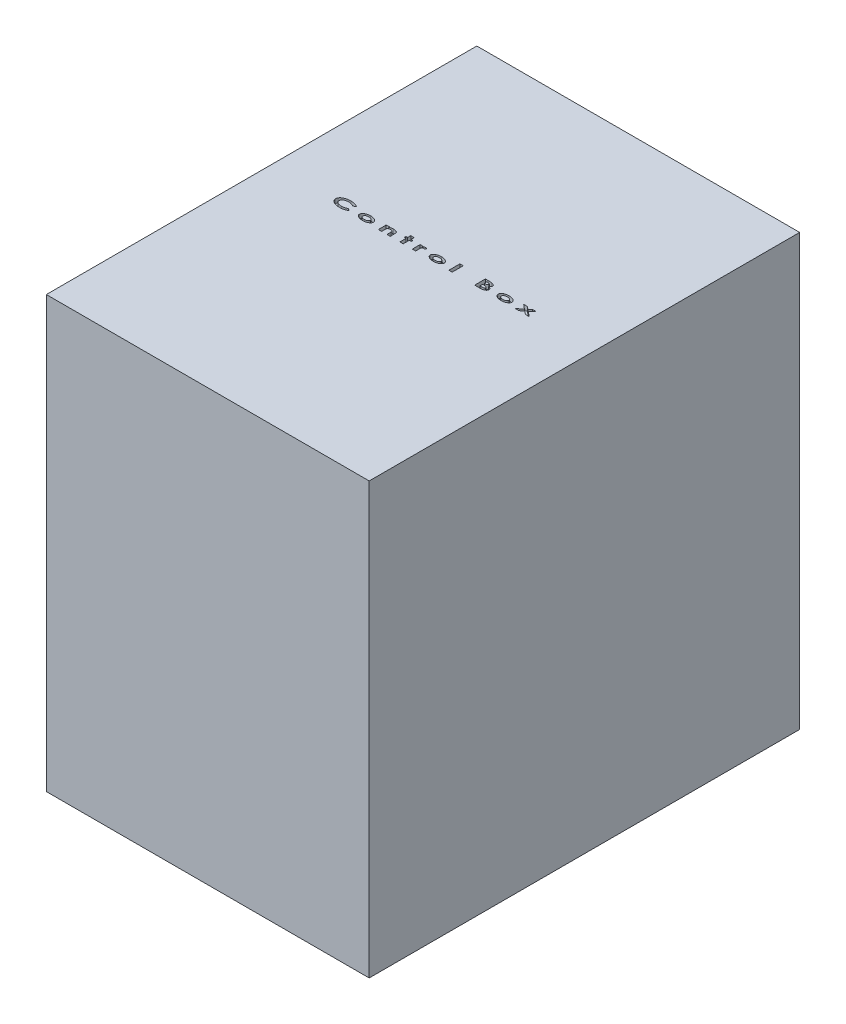
from build123d import *

# Parameters (mm, degrees)
SKETCH1_W           = 150
SKETCH1_H           = 200
BOSS_EXTRUDE1_DEPTH = 200
SKETCH5_W           = 1.538461538
SKETCH5_H           = 5.128205128
CUT_EXTRUDE1_DEPTH  = 2


with BuildPart() as part:
    # Sketch1 → Boss-Extrude1 (new body)
    with BuildSketch(Plane(origin=(0, 0, 0), x_dir=(1, 0, 0), z_dir=(0, 1, 0))):
        with Locations((3.387096774, 4.032258065)):
            Rectangle(SKETCH1_W, SKETCH1_H)
    extrude(amount=BOSS_EXTRUDE1_DEPTH)

    # Sketch5 → Cut-Extrude1 (cut)
    with BuildSketch(Plane(origin=(0, 200, 0), x_dir=(1, 0, 0), z_dir=(0, 1, 0))):
        with BuildLine():
            Line((-34.940086456, 11.453408643), (-36.047858891, 10.824402233))
            add(Edge.make_bspline(
                [(-36.047858891, 10.824402233), (-36.142518363, 10.882607239), (-36.331333147, 10.99870725), (-36.628305726, 11.14641812), (-36.934151745, 11.270341641), (-37.247432659, 11.375064909), (-37.570982515, 11.453348387), (-37.902861291, 11.510511466), (-38.243615225, 11.545606536), (-38.473657359, 11.549564994), (-38.589926199, 11.551565695)],
                knots=[0, 0, 0, 0, 0.000333243, 0.000664712, 0.000993555, 0.001322643, 0.001654724, 0.001991134, 0.002332381, 0.002681113, 0.002681113, 0.002681113, 0.002681113], degree=3))
            add(Edge.make_bspline(
                [(-38.589926199, 11.551565695), (-38.687458788, 11.549988829), (-38.878795575, 11.546895377), (-39.159821776, 11.523738404), (-39.428713565, 11.484673719), (-39.68622642, 11.430982633), (-39.93179496, 11.360679845), (-40.166181353, 11.275912126), (-40.388214953, 11.174043662), (-40.596736069, 11.059290251), (-40.787389507, 10.933495209), (-40.954596669, 10.798410397), (-41.096441269, 10.655821362), (-41.212028332, 10.505402128), (-41.302767967, 10.347627171), (-41.367429412, 10.181995958), (-41.406908919, 10.008604551), (-41.411917667, 9.890444348), (-41.41444543, 9.83081249)],
                knots=[0, 0, 0, 0, 0.000292578, 0.000573971, 0.000845228, 0.00110728, 0.001362493, 0.00161091, 0.001854285, 0.002094578, 0.002324314, 0.002538622, 0.002738351, 0.00292626, 0.00310615, 0.003282478, 0.00345793, 0.00363669, 0.00363669, 0.00363669, 0.00363669], degree=3))
            add(Edge.make_bspline(
                [(-41.41444543, 9.83081249), (-41.413253838, 9.789019266), (-41.410898797, 9.706419854), (-41.39321482, 9.58436284), (-41.365293839, 9.465968917), (-41.326289537, 9.350967355), (-41.274432848, 9.240307857), (-41.211997759, 9.132801978), (-41.138816761, 9.028134812), (-41.053444829, 8.928402077), (-40.958005648, 8.833348763), (-40.853454156, 8.742696327), (-40.738940823, 8.657896739), (-40.61574743, 8.577539652), (-40.482698911, 8.503358074), (-40.34043434, 8.434471768), (-40.188917119, 8.370535686), (-40.02937831, 8.311331356), (-39.862218893, 8.260099724), (-39.690120662, 8.213351644), (-39.512773481, 8.175763545), (-39.331253654, 8.14507952), (-39.145651975, 8.119201968), (-38.955049781, 8.103249962), (-38.760020724, 8.091131621), (-38.628341043, 8.090397666), (-38.561881327, 8.090027233)],
                knots=[0, 0, 0, 0, 0.000125344, 0.000247729, 0.0003692, 0.000489879, 0.000611321, 0.000735184, 0.000862451, 0.000993905, 0.001128471, 0.001266227, 0.001408655, 0.001555618, 0.001707188, 0.001865317, 0.002029583, 0.002200388, 0.002375577, 0.002553907, 0.00273523, 0.00291916, 0.003106141, 0.003297206, 0.003492829, 0.00369217, 0.00369217, 0.00369217, 0.00369217], degree=3))
            add(Edge.make_bspline(
                [(-38.561881327, 8.090027233), (-38.449307157, 8.091967203), (-38.2287817, 8.095767477), (-37.905480838, 8.125038508), (-37.597312164, 8.17402186), (-37.34947334, 8.231076545), (-37.155112027, 8.288709427), (-37.007482101, 8.341322462), (-36.85567906, 8.400415908), (-36.70067376, 8.467585835), (-36.54186218, 8.542833804), (-36.380348012, 8.627272764), (-36.214436595, 8.718323381), (-36.104096085, 8.783812757), (-36.047858891, 8.817190695)],
                knots=[0, 0, 0, 0, 0.000337689, 0.00066151, 0.000972894, 0.001273188, 0.001423712, 0.001580832, 0.00174321, 0.001912341, 0.002087518, 0.002270294, 0.002459026, 0.002655202, 0.002655202, 0.002655202, 0.002655202], degree=3))
            Line((-36.047858891, 8.817190695), (-34.974140943, 8.147118579))
            add(Edge.make_bspline(
                [(-34.974140943, 8.147118579), (-35.049687253, 8.103619875), (-35.198625273, 8.01786306), (-35.422899403, 7.898532232), (-35.644820916, 7.790589572), (-35.862529414, 7.691161807), (-36.077442712, 7.602247119), (-36.289842345, 7.526034682), (-36.498093627, 7.456788137), (-36.705591511, 7.399730237), (-36.914674905, 7.349993594), (-37.129635824, 7.308297967), (-37.351371219, 7.27207744), (-37.580611734, 7.243402992), (-37.816704981, 7.220047947), (-38.060586574, 7.204619368), (-38.311385572, 7.193982797), (-38.481073851, 7.193058683), (-38.56688934, 7.192591336)],
                knots=[0, 0, 0, 0, 0.000261512, 0.000515566, 0.000761938, 0.001001748, 0.001233506, 0.001459418, 0.001678602, 0.00189172, 0.002104781, 0.002323213, 0.002548474, 0.002778679, 0.003016177, 0.003260093, 0.003511695, 0.003769124, 0.003769124, 0.003769124, 0.003769124], degree=3))
            add(Edge.make_bspline(
                [(-38.56688934, 7.192591336), (-38.646359916, 7.193132112), (-38.803683353, 7.194202657), (-39.036766173, 7.203822916), (-39.264253217, 7.21731823), (-39.486026619, 7.237488402), (-39.702502567, 7.263325086), (-39.913487452, 7.295711101), (-40.119534119, 7.332024157), (-40.319648177, 7.376909017), (-40.514750186, 7.425001654), (-40.703755831, 7.481185006), (-40.88812271, 7.540136508), (-41.066093062, 7.607908997), (-41.239036651, 7.679875796), (-41.406460583, 7.758066717), (-41.568368211, 7.842204482), (-41.724517794, 7.930713666), (-41.872177956, 8.024921008), (-42.01196448, 8.121913309), (-42.141682638, 8.222578548), (-42.261796827, 8.326795397), (-42.373402632, 8.432961633), (-42.472981891, 8.545000305), (-42.565313192, 8.657992419), (-42.646214217, 8.775693609), (-42.718509264, 8.896085699), (-42.782243225, 9.019075095), (-42.834265065, 9.146379058), (-42.877283184, 9.276599996), (-42.911667796, 9.410026793), (-42.935602612, 9.546653151), (-42.949856496, 9.686611059), (-42.951882064, 9.781033229), (-42.952906968, 9.828809284)],
                knots=[0, 0, 0, 0, 0.0002384, 0.000471948, 0.000699744, 0.000922002, 0.00113991, 0.001353665, 0.001562311, 0.001767422, 0.001968806, 0.002165, 0.002358846, 0.002549343, 0.002736103, 0.002920716, 0.003103492, 0.003283382, 0.003458991, 0.003628762, 0.00379365, 0.003951287, 0.004105709, 0.004255351, 0.004400669, 0.0045432, 0.004683367, 0.004821784, 0.004958311, 0.005095457, 0.005232954, 0.005371277, 0.005511204, 0.005654521, 0.005654521, 0.005654521, 0.005654521], degree=3))
            add(Edge.make_bspline(
                [(-42.952906968, 9.828809284), (-42.951123925, 9.890334178), (-42.947580603, 10.01259849), (-42.920788993, 10.192755445), (-42.877968267, 10.36825239), (-42.815034908, 10.537208966), (-42.736432511, 10.702103503), (-42.640269624, 10.861203759), (-42.525600222, 11.014584047), (-42.394252177, 11.162267755), (-42.247157011, 11.304947684), (-42.082661497, 11.438342149), (-41.905436988, 11.567684398), (-41.711403596, 11.686890717), (-41.503401545, 11.800800468), (-41.279959875, 11.90619921), (-41.041788394, 12.005782529), (-40.789966843, 12.096917717), (-40.528045319, 12.179664609), (-40.25934907, 12.251807584), (-39.985642159, 12.312790344), (-39.707053569, 12.363322186), (-39.423489855, 12.400479886), (-39.135294071, 12.42934725), (-38.841837219, 12.445013698), (-38.644363029, 12.447665385), (-38.544854084, 12.449001592)],
                knots=[0, 0, 0, 0, 0.000184515, 0.000366675, 0.000545224, 0.000725527, 0.000906518, 0.001092549, 0.001282254, 0.00148022, 0.001684932, 0.001896279, 0.002115062, 0.002342691, 0.002578903, 0.00282621, 0.003083468, 0.003353107, 0.003629335, 0.003907283, 0.004187464, 0.004470377, 0.004756374, 0.005045199, 0.005339106, 0.005637644, 0.005637644, 0.005637644, 0.005637644], degree=3))
            add(Edge.make_bspline(
                [(-38.544854084, 12.449001592), (-38.460036404, 12.448246306), (-38.290983991, 12.446740924), (-38.038466458, 12.434150442), (-37.788159791, 12.414816541), (-37.540486656, 12.384812707), (-37.295030662, 12.349797276), (-37.052475166, 12.303691351), (-36.811640091, 12.252394465), (-36.574632751, 12.191138906), (-36.34232455, 12.123424523), (-36.117589973, 12.048284967), (-35.900258261, 11.967623216), (-35.692262201, 11.877849149), (-35.49154489, 11.783410093), (-35.299806932, 11.680351584), (-35.115199406, 11.572282823), (-34.998097569, 11.492789074), (-34.940086456, 11.453408643)],
                knots=[0, 0, 0, 0, 0.000254439, 0.000507128, 0.000758329, 0.001007424, 0.001255452, 0.001501995, 0.001747957, 0.001994044, 0.002236191, 0.002473742, 0.0027048, 0.002931404, 0.003153174, 0.003370051, 0.003584256, 0.003794547, 0.003794547, 0.003794547, 0.003794547], degree=3))
        make_face()
        with BuildLine():
            add(Edge.make_bspline(
                [(-27.989966263, 11.038745182), (-27.91683363, 11.037981755), (-27.771804367, 11.036467803), (-27.555952648, 11.024154129), (-27.343554207, 11.003799985), (-27.134194849, 10.977522073), (-26.928441668, 10.941059553), (-26.726135081, 10.896640634), (-26.526563738, 10.846388986), (-26.33247435, 10.785882703), (-26.144741213, 10.720539128), (-25.966356963, 10.648780273), (-25.798943328, 10.570085946), (-25.640841808, 10.487836851), (-25.495244962, 10.397041813), (-25.358488831, 10.30305797), (-25.233683015, 10.201812544), (-25.119383038, 10.095907635), (-25.017336872, 9.986284537), (-24.92840151, 9.87347773), (-24.853193681, 9.758556024), (-24.791279809, 9.64126154), (-24.742804271, 9.521914148), (-24.708578591, 9.399989182), (-24.687948423, 9.275959671), (-24.685102478, 9.192534069), (-24.683676199, 9.150724349)],
                knots=[0, 0, 0, 0, 0.000219388, 0.000435067, 0.00064835, 0.000859424, 0.001067895, 0.001274963, 0.001480723, 0.001685072, 0.00188464, 0.002076958, 0.002261571, 0.002439445, 0.002611231, 0.002775997, 0.002936959, 0.003092875, 0.003243129, 0.003385793, 0.003523308, 0.003654579, 0.003783101, 0.003908989, 0.004033804, 0.0041592, 0.0041592, 0.0041592, 0.0041592], degree=3))
            add(Edge.make_bspline(
                [(-24.683676199, 9.150724349), (-24.685137243, 9.108592051), (-24.68805248, 9.02452502), (-24.70817434, 8.899250488), (-24.744404428, 8.776977902), (-24.790984109, 8.655474), (-24.853913844, 8.537549413), (-24.929861776, 8.421405672), (-25.019321283, 8.307165528), (-25.121994564, 8.195828896), (-25.236606593, 8.088967853), (-25.360519679, 7.986046272), (-25.496657917, 7.891859837), (-25.640627981, 7.800910388), (-25.795606529, 7.718049376), (-25.960367868, 7.641170764), (-26.134462516, 7.568651157), (-26.318277609, 7.504280815), (-26.509182546, 7.446506133), (-26.705529166, 7.395158052), (-26.906764768, 7.352327479), (-27.11290845, 7.317085439), (-27.323784897, 7.290181634), (-27.53965878, 7.271584004), (-27.760113723, 7.25886651), (-27.908818288, 7.25742319), (-27.983956648, 7.2566939)],
                knots=[0, 0, 0, 0, 0.000126397, 0.0002522, 0.000379325, 0.000508407, 0.000641918, 0.000779433, 0.000924292, 0.001076697, 0.001233296, 0.001394115, 0.001559456, 0.001729539, 0.001904763, 0.00208623, 0.00227484, 0.002470296, 0.002670228, 0.002873079, 0.003078956, 0.003287256, 0.003500317, 0.003716501, 0.003937181, 0.004162578, 0.004162578, 0.004162578, 0.004162578], degree=3))
            add(Edge.make_bspline(
                [(-27.983956648, 7.2566939), (-28.093843333, 7.258546395), (-28.309564873, 7.26218308), (-28.627040339, 7.287201236), (-28.932075298, 7.330220809), (-29.225149628, 7.390281212), (-29.506298234, 7.466745403), (-29.774274748, 7.562774947), (-30.030921587, 7.673567396), (-30.234014718, 7.781402567), (-30.387447619, 7.874937229), (-30.495575093, 7.946034844), (-30.595163554, 8.020068892), (-30.687943964, 8.095372189), (-30.77326415, 8.172554321), (-30.851216638, 8.251427418), (-30.922288683, 8.332007052), (-30.984778188, 8.41519015), (-31.042011481, 8.499353955), (-31.089354508, 8.586753576), (-31.131274452, 8.674981578), (-31.16403373, 8.765701377), (-31.190445552, 8.857630925), (-31.208313552, 8.951860812), (-31.219621848, 9.04761761), (-31.221297798, 9.112298463), (-31.222137738, 9.144714733)],
                knots=[0, 0, 0, 0, 0.000329651, 0.000647146, 0.000954664, 0.001253242, 0.001544102, 0.001827954, 0.002106511, 0.00238207, 0.002516915, 0.002645534, 0.002770136, 0.002889023, 0.003003898, 0.003115094, 0.003221566, 0.003325934, 0.003427052, 0.003526574, 0.003623812, 0.003719825, 0.003815581, 0.003910459, 0.004007242, 0.00410448, 0.00410448, 0.00410448, 0.00410448], degree=3))
            add(Edge.make_bspline(
                [(-31.222137738, 9.144714733), (-31.221471318, 9.179482111), (-31.220146494, 9.248598696), (-31.206317577, 9.351049634), (-31.185618845, 9.451265318), (-31.156182366, 9.549008745), (-31.119168805, 9.644691933), (-31.072802217, 9.738151293), (-31.017363536, 9.829261786), (-30.954041098, 9.91856634), (-30.88295717, 10.00574795), (-30.803219998, 10.090336675), (-30.714884577, 10.172232281), (-30.61846925, 10.252290618), (-30.514348307, 10.330952472), (-30.400342136, 10.405257858), (-30.279631342, 10.480324855), (-30.194110886, 10.525754115), (-30.150422994, 10.548961528)],
                knots=[0, 0, 0, 0, 0.000104244, 0.000207234, 0.000309579, 0.000410983, 0.000513097, 0.000617018, 0.000723518, 0.000832734, 0.000945209, 0.001060706, 0.001181182, 0.001306346, 0.001436554, 0.001572396, 0.001714458, 0.00186282, 0.00186282, 0.00186282, 0.00186282], degree=3))
            add(Edge.make_bspline(
                [(-30.150422994, 10.548961528), (-30.071170863, 10.58854834), (-29.912128223, 10.667990888), (-29.662711469, 10.765955091), (-29.405646502, 10.850599586), (-29.139760361, 10.919885199), (-28.864658974, 10.972637719), (-28.580750063, 11.010448088), (-28.288175486, 11.03405283), (-28.090170938, 11.037168451), (-27.989966263, 11.038745182)],
                knots=[0, 0, 0, 0, 0.000265653, 0.000533111, 0.000802972, 0.001077247, 0.001356773, 0.00164277, 0.001936144, 0.002236731, 0.002236731, 0.002236731, 0.002236731], degree=3))
        make_face()
        with BuildLine():
            add(Edge.make_bspline(
                [(-27.955911776, 10.205411849), (-28.01635418, 10.204250636), (-28.135041162, 10.201970434), (-28.30917575, 10.189986766), (-28.47512024, 10.164797837), (-28.634051729, 10.133774604), (-28.784687716, 10.091207812), (-28.928635052, 10.041740286), (-29.063312027, 9.979968182), (-29.189971718, 9.91182917), (-29.305239466, 9.836468634), (-29.405417292, 9.754010969), (-29.492296624, 9.667985221), (-29.561747105, 9.574822457), (-29.616962913, 9.47715085), (-29.655191179, 9.373305225), (-29.678946586, 9.264644395), (-29.682090892, 9.190240684), (-29.683676199, 9.152727554)],
                knots=[0, 0, 0, 0, 0.000181359, 0.000356124, 0.000523127, 0.000684594, 0.000841577, 0.000992364, 0.001140743, 0.001285509, 0.001423574, 0.001553102, 0.001674213, 0.001789398, 0.001900593, 0.002009616, 0.002120215, 0.002232681, 0.002232681, 0.002232681, 0.002232681], degree=3))
            add(Edge.make_bspline(
                [(-29.683676199, 9.152727554), (-29.682017327, 9.113900832), (-29.678758036, 9.037615494), (-29.656517756, 8.926043435), (-29.617892721, 8.820381775), (-29.563107681, 8.721010646), (-29.494020556, 8.626853718), (-29.410199281, 8.538066348), (-29.310141476, 8.456083908), (-29.195978495, 8.380731881), (-29.070861838, 8.311932451), (-28.93564283, 8.253353221), (-28.793450639, 8.201646224), (-28.642529292, 8.161062104), (-28.48394477, 8.129093956), (-28.317071661, 8.105874443), (-28.142068908, 8.093356653), (-28.02270351, 8.091150586), (-27.961921391, 8.090027233)],
                knots=[0, 0, 0, 0, 0.000116462, 0.00022882, 0.000339722, 0.000452673, 0.000568066, 0.000689227, 0.000817982, 0.000955213, 0.001099099, 0.001245747, 0.00139687, 0.001552622, 0.001714088, 0.001881942, 0.002057706, 0.002240066, 0.002240066, 0.002240066, 0.002240066], degree=3))
            add(Edge.make_bspline(
                [(-27.961921391, 8.090027233), (-27.900795423, 8.091010613), (-27.781383609, 8.092931681), (-27.606159878, 8.107313652), (-27.438928579, 8.130118164), (-27.279113851, 8.161696418), (-27.127351081, 8.204236747), (-26.983179344, 8.254797282), (-26.846802096, 8.315316584), (-26.719792424, 8.384626514), (-26.60404563, 8.461181173), (-26.501648932, 8.542980168), (-26.416012274, 8.631892557), (-26.344765153, 8.725212531), (-26.290181952, 8.824611187), (-26.250308241, 8.928915721), (-26.226880557, 9.039179365), (-26.223732071, 9.114557494), (-26.222137738, 9.152727554)],
                knots=[0, 0, 0, 0, 0.000183362, 0.000358204, 0.00052705, 0.000689498, 0.000846482, 0.000999491, 0.001147461, 0.001293585, 0.001433038, 0.001563343, 0.001685887, 0.001802473, 0.001914545, 0.002024858, 0.002136437, 0.0022509, 0.0022509, 0.0022509, 0.0022509], degree=3))
            add(Edge.make_bspline(
                [(-26.222137738, 9.152727554), (-26.223811081, 9.190888098), (-26.227112636, 9.266179932), (-26.249344823, 9.376401254), (-26.28766207, 9.480919029), (-26.343094019, 9.578577877), (-26.411765354, 9.671969466), (-26.496665602, 9.759103486), (-26.596978264, 9.840257429), (-26.710488956, 9.91603236), (-26.836553226, 9.982931685), (-26.970900934, 10.043928412), (-27.114673132, 10.093329388), (-27.266551237, 10.13464705), (-27.426908482, 10.166280395), (-27.595754944, 10.189576879), (-27.773096244, 10.202102649), (-27.894128558, 10.204293492), (-27.955911776, 10.205411849)],
                knots=[0, 0, 0, 0, 0.000114463, 0.00022584, 0.000335802, 0.000446998, 0.000561584, 0.000682712, 0.000810831, 0.000948061, 0.001091469, 0.001238524, 0.001390256, 0.001546974, 0.001710404, 0.001880243, 0.002058004, 0.002243368, 0.002243368, 0.002243368, 0.002243368], degree=3))
        make_face(mode=Mode.SUBTRACT)
        with BuildLine():
            Line((-20.645214661, 10.974642618), (-19.106753122, 10.974642618))
            Line((-19.106753122, 10.974642618), (-19.106753122, 10.588024028))
            add(Edge.make_bspline(
                [(-19.106753122, 10.588024028), (-19.020356851, 10.628032281), (-18.853266433, 10.705408257), (-18.604490028, 10.802151719), (-18.36901827, 10.881152948), (-18.143537244, 10.941428536), (-17.922865934, 10.984701263), (-17.702524661, 11.015552322), (-17.479520683, 11.035602518), (-17.329952717, 11.037694096), (-17.254789981, 11.038745182)],
                knots=[0, 0, 0, 0, 0.000285569, 0.000552291, 0.000800294, 0.001030369, 0.001251943, 0.001474472, 0.001697641, 0.001923081, 0.001923081, 0.001923081, 0.001923081], degree=3))
            add(Edge.make_bspline(
                [(-17.254789981, 11.038745182), (-17.17864203, 11.037518176), (-17.02949018, 11.035114826), (-16.809958527, 11.01839433), (-16.599421725, 10.987768227), (-16.397072924, 10.947641111), (-16.203925837, 10.893779493), (-16.018996567, 10.830344654), (-15.843243312, 10.753279512), (-15.732268919, 10.692344328), (-15.677265943, 10.662142618)],
                knots=[0, 0, 0, 0, 0.000228444, 0.000447457, 0.000659929, 0.000866378, 0.001065878, 0.001261003, 0.0014525, 0.001640684, 0.001640684, 0.001640684, 0.001640684], degree=3))
            add(Edge.make_bspline(
                [(-15.677265943, 10.662142618), (-15.633736904, 10.634864487), (-15.549216994, 10.581898808), (-15.438370722, 10.48591041), (-15.342458411, 10.382890977), (-15.265995425, 10.267760898), (-15.204660156, 10.143881002), (-15.16362276, 10.009131971), (-15.13609668, 9.865989122), (-15.133647251, 9.767179678), (-15.132394148, 9.716629797)],
                knots=[0, 0, 0, 0, 0.000153898, 0.000298823, 0.000438492, 0.00057489, 0.000711963, 0.000851661, 0.000996253, 0.001147707, 0.001147707, 0.001147707, 0.001147707], degree=3))
            Line((-15.132394148, 9.716629797), (-15.132394148, 7.320796464))
            Line((-15.132394148, 7.320796464), (-16.670855686, 7.320796464))
            Line((-16.670855686, 7.320796464), (-16.670855686, 8.907334925))
            add(Edge.make_bspline(
                [(-16.670855686, 8.907334925), (-16.671411632, 8.959084967), (-16.672477055, 9.058259583), (-16.675765871, 9.200240454), (-16.683858639, 9.328508576), (-16.694827866, 9.443080329), (-16.707910286, 9.544268105), (-16.726398959, 9.631330214), (-16.745333054, 9.705586033), (-16.777394063, 9.785187583), (-16.828391518, 9.871451276), (-16.907539432, 9.961059171), (-17.007347926, 10.035688878), (-17.12418709, 10.09725089), (-17.257239038, 10.146218972), (-17.405586171, 10.180660564), (-17.568683355, 10.201824982), (-17.68240587, 10.204184391), (-17.741568827, 10.205411849)],
                knots=[0, 0, 0, 0, 0.000155261, 0.000297545, 0.000426001, 0.000540714, 0.000642843, 0.000731828, 0.000807639, 0.000872365, 0.000988658, 0.001106439, 0.001228639, 0.001360379, 0.001501406, 0.001652758, 0.001816375, 0.001993797, 0.001993797, 0.001993797, 0.001993797], degree=3))
            add(Edge.make_bspline(
                [(-17.741568827, 10.205411849), (-17.818477837, 10.203047597), (-17.967744777, 10.198458999), (-18.183300533, 10.164729349), (-18.381944187, 10.106328825), (-18.53385031, 10.03829465), (-18.645031935, 9.973540678), (-18.721033778, 9.92056154), (-18.790473066, 9.863382086), (-18.853256691, 9.801794994), (-18.909191141, 9.735472035), (-18.959820125, 9.665242553), (-19.003124894, 9.590032929), (-19.026120576, 9.536914578), (-19.037642545, 9.510299669)],
                knots=[0, 0, 0, 0, 0.000230682, 0.000447713, 0.000652442, 0.000850144, 0.000945312, 0.001038116, 0.001127758, 0.001214874, 0.001301569, 0.001387731, 0.001474321, 0.001561276, 0.001561276, 0.001561276, 0.001561276], degree=3))
            add(Edge.make_bspline(
                [(-19.037642545, 9.510299669), (-19.043291609, 9.494029375), (-19.055799622, 9.458004108), (-19.068968766, 9.396464821), (-19.080799354, 9.323256534), (-19.090985825, 9.237732155), (-19.097017608, 9.139408557), (-19.103676094, 9.02894196), (-19.10613302, 8.906009546), (-19.106539585, 8.820195122), (-19.106753122, 8.775123387)],
                knots=[0, 0, 0, 0, 5.1629e-05, 0.000114315, 0.000188413, 0.000274137, 0.000372544, 0.000483884, 0.000606116, 0.000741336, 0.000741336, 0.000741336, 0.000741336], degree=3))
            Line((-19.106753122, 8.775123387), (-19.106753122, 7.320796464))
            Line((-19.106753122, 7.320796464), (-20.645214661, 7.320796464))
            Line((-20.645214661, 7.320796464), (-20.645214661, 10.974642618))
        make_face()
        Polygon((-10.645214661, 12.384899028), (-9.106753122, 12.384899028), (-9.106753122, 10.974642618), (-8.209317225, 10.974642618), (-8.209317225, 10.205411849), (-9.106753122, 10.205411849), (-9.106753122, 7.320796464), (-10.645214661, 7.320796464), (-10.645214661, 10.205411849), (-11.41444543, 10.205411849), (-11.41444543, 10.974642618), (-10.645214661, 10.974642618), align=None)
        with BuildLine():
            Line((-4.875983891, 10.974642618), (-3.529830045, 10.974642618))
            Line((-3.529830045, 10.974642618), (-3.529830045, 10.524923067))
            add(Edge.make_bspline(
                [(-3.529830045, 10.524923067), (-3.493133996, 10.565371374), (-3.419045327, 10.647035786), (-3.28745397, 10.751463829), (-3.138083919, 10.838621548), (-2.974119243, 10.911442854), (-2.797235795, 10.967708669), (-2.610854568, 11.008719783), (-2.416438597, 11.034548999), (-2.283917383, 11.03733346), (-2.216729084, 11.038745182)],
                knots=[0, 0, 0, 0, 0.000163642, 0.00033039, 0.000501479, 0.00068128, 0.00086753, 0.001057322, 0.00125324, 0.001454721, 0.001454721, 0.001454721, 0.001454721], degree=3))
            add(Edge.make_bspline(
                [(-2.216729084, 11.038745182), (-2.167618808, 11.037354337), (-2.067821719, 11.034527999), (-1.916314555, 11.018657764), (-1.761954521, 10.988952114), (-1.659032506, 10.962193187), (-1.606753122, 10.948600951)],
                knots=[0, 0, 0, 0, 0.000147358, 0.000299447, 0.000456405, 0.000618435, 0.000618435, 0.000618435, 0.000618435], degree=3))
            Line((-1.606753122, 10.948600951), (-2.076504725, 10.188384605))
            add(Edge.make_bspline(
                [(-2.076504725, 10.188384605), (-2.118813547, 10.200413774), (-2.198675589, 10.223120006), (-2.313688951, 10.250193251), (-2.417275858, 10.265932738), (-2.482778677, 10.268378435), (-2.513203443, 10.269514413)],
                knots=[0, 0, 0, 0, 0.000131946, 0.00024906, 0.000354305, 0.000445588, 0.000445588, 0.000445588, 0.000445588], degree=3))
            add(Edge.make_bspline(
                [(-2.513203443, 10.269514413), (-2.541618195, 10.268738821), (-2.597706172, 10.267207878), (-2.680464254, 10.255202634), (-2.759396649, 10.233707228), (-2.83569085, 10.205892132), (-2.907705636, 10.168446187), (-2.976772411, 10.123046912), (-3.041195199, 10.068245334), (-3.104996757, 10.007453366), (-3.162094151, 9.932634205), (-3.21107189, 9.842442247), (-3.251461593, 9.736103491), (-3.285328712, 9.614757022), (-3.310645411, 9.477603338), (-3.329617811, 9.325122612), (-3.340157346, 9.15688152), (-3.341717626, 9.039560463), (-3.342530366, 8.978448708)],
                knots=[0, 0, 0, 0, 8.523e-05, 0.000168237, 0.000250111, 0.000330296, 0.000411376, 0.000493048, 0.000577688, 0.000664804, 0.000756957, 0.000858717, 0.000971619, 0.001097506, 0.001236191, 0.00138962, 0.001558249, 0.001741586, 0.001741586, 0.001741586, 0.001741586], degree=3))
            Line((-3.342530366, 8.978448708), (-3.337522353, 8.800163451))
            Line((-3.337522353, 8.800163451), (-3.337522353, 7.320796464))
            Line((-3.337522353, 7.320796464), (-4.875983891, 7.320796464))
            Line((-4.875983891, 7.320796464), (-4.875983891, 10.974642618))
        make_face()
        with BuildLine():
            add(Edge.make_bspline(
                [(4.894649121, 11.038745182), (4.967781755, 11.037981755), (5.112811017, 11.036467803), (5.328662736, 11.024154129), (5.541061178, 11.003799985), (5.750420536, 10.977522073), (5.956173717, 10.941059553), (6.158480303, 10.896640634), (6.358051647, 10.846388986), (6.552141035, 10.785882703), (6.739874171, 10.720539128), (6.918258421, 10.648780273), (7.085672056, 10.570085946), (7.243773577, 10.487836851), (7.389370423, 10.397041813), (7.526126554, 10.30305797), (7.650932369, 10.201812544), (7.765232346, 10.095907635), (7.867278512, 9.986284537), (7.956213875, 9.87347773), (8.031421704, 9.758556024), (8.093335576, 9.64126154), (8.141811114, 9.521914148), (8.176036793, 9.399989182), (8.196666962, 9.275959671), (8.199512907, 9.192534069), (8.200939185, 9.150724349)],
                knots=[0, 0, 0, 0, 0.000219388, 0.000435067, 0.00064835, 0.000859424, 0.001067895, 0.001274963, 0.001480723, 0.001685072, 0.00188464, 0.002076958, 0.002261571, 0.002439445, 0.002611231, 0.002775997, 0.002936959, 0.003092875, 0.003243129, 0.003385793, 0.003523308, 0.003654579, 0.003783101, 0.003908989, 0.004033804, 0.0041592, 0.0041592, 0.0041592, 0.0041592], degree=3))
            add(Edge.make_bspline(
                [(8.200939185, 9.150724349), (8.199478141, 9.108592051), (8.196562905, 9.02452502), (8.176441044, 8.899250488), (8.140210957, 8.776977902), (8.093631276, 8.655474), (8.030701541, 8.537549413), (7.954753609, 8.421405672), (7.865294102, 8.307165528), (7.762620821, 8.195828896), (7.648008792, 8.088967853), (7.524095705, 7.986046272), (7.387957468, 7.891859837), (7.243987404, 7.800910388), (7.089008856, 7.718049376), (6.924247517, 7.641170764), (6.750152869, 7.568651157), (6.566337776, 7.504280815), (6.375432838, 7.446506133), (6.179086218, 7.395158052), (5.977850616, 7.352327479), (5.771706935, 7.317085439), (5.560830487, 7.290181634), (5.344956605, 7.271584004), (5.124501661, 7.25886651), (4.975797096, 7.25742319), (4.900658737, 7.2566939)],
                knots=[0, 0, 0, 0, 0.000126397, 0.0002522, 0.000379325, 0.000508407, 0.000641918, 0.000779433, 0.000924292, 0.001076697, 0.001233296, 0.001394115, 0.001559456, 0.001729539, 0.001904763, 0.00208623, 0.00227484, 0.002470296, 0.002670228, 0.002873079, 0.003078956, 0.003287256, 0.003500317, 0.003716501, 0.003937181, 0.004162578, 0.004162578, 0.004162578, 0.004162578], degree=3))
            add(Edge.make_bspline(
                [(4.900658737, 7.2566939), (4.790772051, 7.258546395), (4.575050512, 7.26218308), (4.257575046, 7.287201236), (3.952540087, 7.330220809), (3.659465757, 7.390281212), (3.378317151, 7.466745403), (3.110340636, 7.562774947), (2.853693798, 7.673567396), (2.650600667, 7.781402567), (2.497167766, 7.874937229), (2.389040292, 7.946034844), (2.289451831, 8.020068892), (2.196671421, 8.095372189), (2.111351234, 8.172554321), (2.033398747, 8.251427418), (1.962326702, 8.332007052), (1.899837197, 8.41519015), (1.842603903, 8.499353955), (1.795260876, 8.586753576), (1.753340933, 8.674981578), (1.720581655, 8.765701377), (1.694169833, 8.857630925), (1.676301832, 8.951860812), (1.664993536, 9.04761761), (1.663317587, 9.112298463), (1.662477647, 9.144714733)],
                knots=[0, 0, 0, 0, 0.000329651, 0.000647146, 0.000954664, 0.001253242, 0.001544102, 0.001827954, 0.002106511, 0.00238207, 0.002516915, 0.002645534, 0.002770136, 0.002889023, 0.003003898, 0.003115094, 0.003221566, 0.003325934, 0.003427052, 0.003526574, 0.003623812, 0.003719825, 0.003815581, 0.003910459, 0.004007242, 0.00410448, 0.00410448, 0.00410448, 0.00410448], degree=3))
            add(Edge.make_bspline(
                [(1.662477647, 9.144714733), (1.663144067, 9.179482111), (1.664468891, 9.248598696), (1.678297808, 9.351049634), (1.69899654, 9.451265318), (1.728433019, 9.549008745), (1.76544658, 9.644691933), (1.811813167, 9.738151293), (1.867251849, 9.829261786), (1.930574287, 9.91856634), (2.001658214, 10.00574795), (2.081395386, 10.090336675), (2.169730807, 10.172232281), (2.266146135, 10.252290618), (2.370267078, 10.330952472), (2.484273248, 10.405257858), (2.604984042, 10.480324855), (2.690504499, 10.525754115), (2.734192391, 10.548961528)],
                knots=[0, 0, 0, 0, 0.000104244, 0.000207234, 0.000309579, 0.000410983, 0.000513097, 0.000617018, 0.000723518, 0.000832734, 0.000945209, 0.001060706, 0.001181182, 0.001306346, 0.001436554, 0.001572396, 0.001714458, 0.00186282, 0.00186282, 0.00186282, 0.00186282], degree=3))
            add(Edge.make_bspline(
                [(2.734192391, 10.548961528), (2.813444522, 10.58854834), (2.972487162, 10.667990888), (3.221903915, 10.765955091), (3.478968882, 10.850599586), (3.744855023, 10.919885199), (4.019956411, 10.972637719), (4.303865321, 11.010448088), (4.596439898, 11.03405283), (4.794444447, 11.037168451), (4.894649121, 11.038745182)],
                knots=[0, 0, 0, 0, 0.000265653, 0.000533111, 0.000802972, 0.001077247, 0.001356773, 0.00164277, 0.001936144, 0.002236731, 0.002236731, 0.002236731, 0.002236731], degree=3))
        make_face()
        with BuildLine():
            add(Edge.make_bspline(
                [(4.928703609, 10.205411849), (4.868261205, 10.204250636), (4.749574223, 10.201970434), (4.575439634, 10.189986766), (4.409495145, 10.164797837), (4.250563656, 10.133774604), (4.099927668, 10.091207812), (3.955980332, 10.041740286), (3.821303358, 9.979968182), (3.694643667, 9.91182917), (3.579375918, 9.836468634), (3.479198092, 9.754010969), (3.39231876, 9.667985221), (3.322868279, 9.574822457), (3.267652472, 9.47715085), (3.229424206, 9.373305225), (3.205668799, 9.264644395), (3.202524493, 9.190240684), (3.200939185, 9.152727554)],
                knots=[0, 0, 0, 0, 0.000181359, 0.000356124, 0.000523127, 0.000684594, 0.000841577, 0.000992364, 0.001140743, 0.001285509, 0.001423574, 0.001553102, 0.001674213, 0.001789398, 0.001900593, 0.002009616, 0.002120215, 0.002232681, 0.002232681, 0.002232681, 0.002232681], degree=3))
            add(Edge.make_bspline(
                [(3.200939185, 9.152727554), (3.202598057, 9.113900832), (3.205857349, 9.037615494), (3.228097629, 8.926043435), (3.266722664, 8.820381775), (3.321507704, 8.721010646), (3.390594829, 8.626853718), (3.474416103, 8.538066348), (3.574473908, 8.456083908), (3.68863689, 8.380731881), (3.813753547, 8.311932451), (3.948972555, 8.253353221), (4.091164746, 8.201646224), (4.242086092, 8.161062104), (4.400670615, 8.129093956), (4.567543724, 8.105874443), (4.742546477, 8.093356653), (4.861911874, 8.091150586), (4.922693993, 8.090027233)],
                knots=[0, 0, 0, 0, 0.000116462, 0.00022882, 0.000339722, 0.000452673, 0.000568066, 0.000689227, 0.000817982, 0.000955213, 0.001099099, 0.001245747, 0.00139687, 0.001552622, 0.001714088, 0.001881942, 0.002057706, 0.002240066, 0.002240066, 0.002240066, 0.002240066], degree=3))
            add(Edge.make_bspline(
                [(4.922693993, 8.090027233), (4.983819962, 8.091010613), (5.103231775, 8.092931681), (5.278455507, 8.107313652), (5.445686806, 8.130118164), (5.605501533, 8.161696418), (5.757264303, 8.204236747), (5.901436041, 8.254797282), (6.037813289, 8.315316584), (6.16482296, 8.384626514), (6.280569755, 8.461181173), (6.382966453, 8.542980168), (6.46860311, 8.631892557), (6.539850232, 8.725212531), (6.594433432, 8.824611187), (6.634307144, 8.928915721), (6.657734828, 9.039179365), (6.660883313, 9.114557494), (6.662477647, 9.152727554)],
                knots=[0, 0, 0, 0, 0.000183362, 0.000358204, 0.00052705, 0.000689498, 0.000846482, 0.000999491, 0.001147461, 0.001293585, 0.001433038, 0.001563343, 0.001685887, 0.001802473, 0.001914545, 0.002024858, 0.002136437, 0.0022509, 0.0022509, 0.0022509, 0.0022509], degree=3))
            add(Edge.make_bspline(
                [(6.662477647, 9.152727554), (6.660804303, 9.190888098), (6.657502749, 9.266179932), (6.635270561, 9.376401254), (6.596953315, 9.480919029), (6.541521366, 9.578577877), (6.47285003, 9.671969466), (6.387949783, 9.759103486), (6.28763712, 9.840257429), (6.174126429, 9.91603236), (6.048062159, 9.982931685), (5.913714451, 10.043928412), (5.769942253, 10.093329388), (5.618064148, 10.13464705), (5.457706903, 10.166280395), (5.288860441, 10.189576879), (5.11151914, 10.202102649), (4.990486827, 10.204293492), (4.928703609, 10.205411849)],
                knots=[0, 0, 0, 0, 0.000114463, 0.00022584, 0.000335802, 0.000446998, 0.000561584, 0.000682712, 0.000810831, 0.000948061, 0.001091469, 0.001238524, 0.001390256, 0.001546974, 0.001710404, 0.001880243, 0.002058004, 0.002243368, 0.002243368, 0.002243368, 0.002243368], degree=3))
        make_face(mode=Mode.SUBTRACT)
        with Locations((12.880426365, 9.884899028)):
            Rectangle(SKETCH5_W, SKETCH5_H)
        with BuildLine():
            Line((24.098375083, 7.320796464), (24.098375083, 12.320796464))
            Line((24.098375083, 12.320796464), (25.409472839, 12.320796464))
            add(Edge.make_bspline(
                [(25.409472839, 12.320796464), (25.501289568, 12.320805544), (25.678928873, 12.320823111), (25.935680186, 12.315281217), (26.173397948, 12.308280589), (26.391854593, 12.300154625), (26.590818286, 12.286661622), (26.770859502, 12.271993618), (26.931649843, 12.254768737), (27.032117983, 12.239023665), (27.079144314, 12.231653836)],
                knots=[0, 0, 0, 0, 0.000275443, 0.000532903, 0.000770386, 0.000988922, 0.001188666, 0.001368581, 0.001530844, 0.001673627, 0.001673627, 0.001673627, 0.001673627], degree=3))
            add(Edge.make_bspline(
                [(27.079144314, 12.231653836), (27.140029098, 12.221257148), (27.259361699, 12.200879911), (27.432399595, 12.16048373), (27.59616187, 12.114366678), (27.750427765, 12.063080164), (27.89473871, 12.003291712), (28.029661481, 11.937594195), (28.155324539, 11.865520526), (28.270373612, 11.78738062), (28.374634722, 11.70550197), (28.464168028, 11.617514368), (28.54119024, 11.527045147), (28.605194504, 11.432881327), (28.653553228, 11.333878767), (28.687754929, 11.231474126), (28.709904259, 11.125495727), (28.712466083, 11.053210814), (28.713759698, 11.016709925)],
                knots=[0, 0, 0, 0, 0.000185264, 0.000363113, 0.000532751, 0.000695553, 0.000850494, 0.001001005, 0.001145489, 0.001284669, 0.001417942, 0.001542601, 0.001660586, 0.001773926, 0.001883225, 0.001989965, 0.002097216, 0.002206616, 0.002206616, 0.002206616, 0.002206616], degree=3))
            add(Edge.make_bspline(
                [(28.713759698, 11.016709925), (28.711227394, 10.969706446), (28.70618653, 10.876140229), (28.666213199, 10.739873675), (28.601771297, 10.610465524), (28.527529688, 10.510048287), (28.454942892, 10.434147472), (28.392167282, 10.376447435), (28.321560494, 10.319906675), (28.242344976, 10.264496883), (28.155940352, 10.209723875), (28.06067474, 10.156544578), (27.958167137, 10.103645549), (27.886229343, 10.070267391), (27.849376685, 10.053168259)],
                knots=[0, 0, 0, 0, 0.000140828, 0.000280335, 0.000422329, 0.000572777, 0.000652836, 0.000737191, 0.000828386, 0.00092398, 0.001027072, 0.001135157, 0.001251179, 0.001373046, 0.001373046, 0.001373046, 0.001373046], degree=3))
            add(Edge.make_bspline(
                [(27.849376685, 10.053168259), (27.909619379, 10.035266873), (28.026748744, 10.00046136), (28.195068539, 9.942097929), (28.351580045, 9.881696423), (28.49491967, 9.816553705), (28.625612879, 9.748270245), (28.744429437, 9.677754462), (28.849893597, 9.602213794), (28.943605215, 9.524146607), (29.025641265, 9.442541989), (29.096189901, 9.356814196), (29.156412803, 9.267717473), (29.206465188, 9.175137049), (29.243157812, 9.078172783), (29.270331699, 8.97826133), (29.288438945, 8.874602775), (29.289928439, 8.803912426), (29.290682775, 8.768112169)],
                knots=[0, 0, 0, 0, 0.000188517, 0.000366532, 0.000534303, 0.000691634, 0.00083858, 0.000976514, 0.001105755, 0.00122733, 0.001342064, 0.001452354, 0.001559862, 0.001664265, 0.001767313, 0.001870093, 0.001974654, 0.002081942, 0.002081942, 0.002081942, 0.002081942], degree=3))
            add(Edge.make_bspline(
                [(29.290682775, 8.768112169), (29.289470807, 8.733652312), (29.287055726, 8.6649844), (29.269289785, 8.563231893), (29.241398149, 8.463755428), (29.20159093, 8.366427768), (29.150832163, 8.271567144), (29.087269229, 8.179833776), (29.014530322, 8.089200349), (28.929189979, 8.003306967), (28.836318004, 7.920207981), (28.736276212, 7.842211177), (28.62938976, 7.76988328), (28.51624844, 7.70251116), (28.395729694, 7.641842057), (28.269360208, 7.585746275), (28.136875722, 7.534254327), (27.996319778, 7.489225293), (27.845815089, 7.448289567), (27.682285991, 7.41556492), (27.506191938, 7.38445105), (27.315766408, 7.362811016), (27.112153871, 7.343099313), (26.894633406, 7.330858952), (26.66387781, 7.322572859), (26.505568088, 7.321400039), (26.424096237, 7.320796464)],
                knots=[0, 0, 0, 0, 0.00010334, 0.000205925, 0.000308973, 0.000412759, 0.000520755, 0.000631045, 0.000747115, 0.00086894, 0.000993791, 0.001120817, 0.001249163, 0.001380744, 0.001515574, 0.001653679, 0.001795415, 0.001941752, 0.002096275, 0.00226305, 0.002441875, 0.002632574, 0.002837785, 0.003055523, 0.003286031, 0.00353044, 0.00353044, 0.00353044, 0.00353044], degree=3))
            Line((26.424096237, 7.320796464), (24.098375083, 7.320796464))
        make_face()
        with BuildLine():
            Line((25.636836621, 11.423360567), (25.636836621, 10.333616977))
            Line((25.636836621, 10.333616977), (25.995410339, 10.333616977))
            add(Edge.make_bspline(
                [(25.995410339, 10.333616977), (26.043830363, 10.33389711), (26.137387366, 10.334438382), (26.272723929, 10.341509027), (26.39842466, 10.353246534), (26.514364792, 10.370329499), (26.621180023, 10.391001021), (26.718391114, 10.416678181), (26.805751981, 10.447702971), (26.883570321, 10.482777803), (26.952137225, 10.521810001), (27.011952641, 10.564821403), (27.061776684, 10.612162192), (27.104384985, 10.661269017), (27.135392944, 10.71569765), (27.159082229, 10.772703828), (27.171976823, 10.833860201), (27.174180401, 10.875430958), (27.17529816, 10.896517618)],
                knots=[0, 0, 0, 0, 0.000145246, 0.000280644, 0.00040642, 0.000523847, 0.00063208, 0.000732665, 0.000825171, 0.000909888, 0.000988404, 0.001061528, 0.00113026, 0.001194253, 0.001255752, 0.001317316, 0.001378806, 0.001442105, 0.001442105, 0.001442105, 0.001442105], degree=3))
            add(Edge.make_bspline(
                [(27.17529816, 10.896517618), (27.174611958, 10.91628173), (27.173258659, 10.955259729), (27.160006602, 11.011966754), (27.13697591, 11.064832316), (27.107345971, 11.115536115), (27.066821441, 11.161561014), (27.019998765, 11.206266672), (26.962836129, 11.246084224), (26.897835653, 11.283032862), (26.824041079, 11.316139348), (26.74127021, 11.345130471), (26.649551308, 11.369859867), (26.548829114, 11.389858678), (26.439390367, 11.404421631), (26.320770883, 11.415295475), (26.193149949, 11.422563094), (26.104929356, 11.423089546), (26.059512903, 11.423360567)],
                knots=[0, 0, 0, 0, 5.923e-05, 0.000116811, 0.000173364, 0.000231767, 0.000292171, 0.000356656, 0.000425585, 0.000500498, 0.000580739, 0.000667855, 0.000763344, 0.000865488, 0.000975692, 0.001094393, 0.00122279, 0.001359023, 0.001359023, 0.001359023, 0.001359023], degree=3))
            Line((26.059512903, 11.423360567), (25.636836621, 11.423360567))
        make_face(mode=Mode.SUBTRACT)
        with BuildLine():
            Line((25.636836621, 9.500283643), (25.636836621, 8.218232361))
            Line((25.636836621, 8.218232361), (26.04248566, 8.218232361))
            add(Edge.make_bspline(
                [(26.04248566, 8.218232361), (26.122952495, 8.218515031), (26.277242883, 8.219057033), (26.498686377, 8.225932979), (26.699727635, 8.237964838), (26.880212618, 8.253331076), (27.040046804, 8.273977696), (27.179161376, 8.299733872), (27.298311064, 8.329013619), (27.398535058, 8.363908132), (27.481845928, 8.405335973), (27.554285429, 8.447831181), (27.615163842, 8.496550726), (27.665406828, 8.549216192), (27.704947942, 8.606521672), (27.731637593, 8.668565796), (27.750043511, 8.734341289), (27.751488284, 8.780003306), (27.752221237, 8.803168259)],
                knots=[0, 0, 0, 0, 0.000241395, 0.00046286, 0.00066454, 0.00084554, 0.001006177, 0.001147815, 0.001269764, 0.001373993, 0.001465375, 0.001548514, 0.001625475, 0.001698454, 0.001766239, 0.001833054, 0.001900348, 0.00196964, 0.00196964, 0.00196964, 0.00196964], degree=3))
            add(Edge.make_bspline(
                [(27.752221237, 8.803168259), (27.751313121, 8.829696066), (27.749526375, 8.881890346), (27.72786008, 8.957214122), (27.695696403, 9.02847849), (27.649929262, 9.095249603), (27.590598883, 9.156360327), (27.519597812, 9.214285877), (27.434903739, 9.266480634), (27.337823556, 9.31631396), (27.225523778, 9.36038785), (27.096429258, 9.398074594), (26.950414208, 9.429542401), (26.787484207, 9.454959304), (26.608143589, 9.476437923), (26.411553408, 9.48926449), (26.198162531, 9.498848828), (26.050177325, 9.499793416), (25.973375083, 9.500283643)],
                knots=[0, 0, 0, 0, 7.9354e-05, 0.000156132, 0.000233223, 0.000313232, 0.00039754, 0.000487956, 0.000587438, 0.000695393, 0.000814987, 0.000948723, 0.001098428, 0.001262764, 0.00144328, 0.001640095, 0.001853626, 0.002084015, 0.002084015, 0.002084015, 0.002084015], degree=3))
            Line((25.973375083, 9.500283643), (25.636836621, 9.500283643))
        make_face(mode=Mode.SUBTRACT)
        with BuildLine():
            add(Edge.make_bspline(
                [(36.369008096, 11.038745182), (36.442140729, 11.037981755), (36.587169992, 11.036467803), (36.803021711, 11.024154129), (37.015420152, 11.003799985), (37.22477951, 10.977522073), (37.430532691, 10.941059553), (37.632839278, 10.896640634), (37.832410621, 10.846388986), (38.026500009, 10.785882703), (38.214233145, 10.720539128), (38.392617396, 10.648780273), (38.560031031, 10.570085946), (38.718132551, 10.487836851), (38.863729397, 10.397041813), (39.000485528, 10.30305797), (39.125291344, 10.201812544), (39.239591321, 10.095907635), (39.341637487, 9.986284537), (39.430572849, 9.87347773), (39.505780678, 9.758556024), (39.56769455, 9.64126154), (39.616170088, 9.521914148), (39.650395768, 9.399989182), (39.671025936, 9.275959671), (39.673871881, 9.192534069), (39.67529816, 9.150724349)],
                knots=[0, 0, 0, 0, 0.000219388, 0.000435067, 0.00064835, 0.000859424, 0.001067895, 0.001274963, 0.001480723, 0.001685072, 0.00188464, 0.002076958, 0.002261571, 0.002439445, 0.002611231, 0.002775997, 0.002936959, 0.003092875, 0.003243129, 0.003385793, 0.003523308, 0.003654579, 0.003783101, 0.003908989, 0.004033804, 0.0041592, 0.0041592, 0.0041592, 0.0041592], degree=3))
            add(Edge.make_bspline(
                [(39.67529816, 9.150724349), (39.673837116, 9.108592051), (39.670921879, 9.02452502), (39.650800019, 8.899250488), (39.614569931, 8.776977902), (39.56799025, 8.655474), (39.505060515, 8.537549413), (39.429112583, 8.421405672), (39.339653076, 8.307165528), (39.236979795, 8.195828896), (39.122367766, 8.088967853), (38.99845468, 7.986046272), (38.862316442, 7.891859837), (38.718346378, 7.800910388), (38.56336783, 7.718049376), (38.398606491, 7.641170764), (38.224511843, 7.568651157), (38.04069675, 7.504280815), (37.849791813, 7.446506133), (37.653445193, 7.395158052), (37.452209591, 7.352327479), (37.246065909, 7.317085439), (37.035189462, 7.290181634), (36.819315579, 7.271584004), (36.598860636, 7.25886651), (36.450156071, 7.25742319), (36.375017711, 7.2566939)],
                knots=[0, 0, 0, 0, 0.000126397, 0.0002522, 0.000379325, 0.000508407, 0.000641918, 0.000779433, 0.000924292, 0.001076697, 0.001233296, 0.001394115, 0.001559456, 0.001729539, 0.001904763, 0.00208623, 0.00227484, 0.002470296, 0.002670228, 0.002873079, 0.003078956, 0.003287256, 0.003500317, 0.003716501, 0.003937181, 0.004162578, 0.004162578, 0.004162578, 0.004162578], degree=3))
            add(Edge.make_bspline(
                [(36.375017711, 7.2566939), (36.265131026, 7.258546395), (36.049409486, 7.26218308), (35.73193402, 7.287201236), (35.426899061, 7.330220809), (35.133824731, 7.390281212), (34.852676125, 7.466745403), (34.584699611, 7.562774947), (34.328052772, 7.673567396), (34.124959641, 7.781402567), (33.97152674, 7.874937229), (33.863399266, 7.946034844), (33.763810805, 8.020068892), (33.671030395, 8.095372189), (33.585710209, 8.172554321), (33.507757721, 8.251427418), (33.436685676, 8.332007052), (33.374196171, 8.41519015), (33.316962877, 8.499353955), (33.269619851, 8.586753576), (33.227699907, 8.674981578), (33.194940629, 8.765701377), (33.168528807, 8.857630925), (33.150660806, 8.951860812), (33.13935251, 9.04761761), (33.137676561, 9.112298463), (33.136836621, 9.144714733)],
                knots=[0, 0, 0, 0, 0.000329651, 0.000647146, 0.000954664, 0.001253242, 0.001544102, 0.001827954, 0.002106511, 0.00238207, 0.002516915, 0.002645534, 0.002770136, 0.002889023, 0.003003898, 0.003115094, 0.003221566, 0.003325934, 0.003427052, 0.003526574, 0.003623812, 0.003719825, 0.003815581, 0.003910459, 0.004007242, 0.00410448, 0.00410448, 0.00410448, 0.00410448], degree=3))
            add(Edge.make_bspline(
                [(33.136836621, 9.144714733), (33.137503041, 9.179482111), (33.138827865, 9.248598696), (33.152656782, 9.351049634), (33.173355514, 9.451265318), (33.202791993, 9.549008745), (33.239805554, 9.644691933), (33.286172142, 9.738151293), (33.341610823, 9.829261786), (33.404933261, 9.91856634), (33.476017189, 10.00574795), (33.555754361, 10.090336675), (33.644089782, 10.172232281), (33.740505109, 10.252290618), (33.844626052, 10.330952472), (33.958632223, 10.405257858), (34.079343017, 10.480324855), (34.164863473, 10.525754115), (34.208551365, 10.548961528)],
                knots=[0, 0, 0, 0, 0.000104244, 0.000207234, 0.000309579, 0.000410983, 0.000513097, 0.000617018, 0.000723518, 0.000832734, 0.000945209, 0.001060706, 0.001181182, 0.001306346, 0.001436554, 0.001572396, 0.001714458, 0.00186282, 0.00186282, 0.00186282, 0.00186282], degree=3))
            add(Edge.make_bspline(
                [(34.208551365, 10.548961528), (34.287803496, 10.58854834), (34.446846136, 10.667990888), (34.69626289, 10.765955091), (34.953327857, 10.850599586), (35.219213998, 10.919885199), (35.494315385, 10.972637719), (35.778224296, 11.010448088), (36.070798873, 11.03405283), (36.268803421, 11.037168451), (36.369008096, 11.038745182)],
                knots=[0, 0, 0, 0, 0.000265653, 0.000533111, 0.000802972, 0.001077247, 0.001356773, 0.00164277, 0.001936144, 0.002236731, 0.002236731, 0.002236731, 0.002236731], degree=3))
        make_face()
        with BuildLine():
            add(Edge.make_bspline(
                [(36.403062583, 10.205411849), (36.342620179, 10.204250636), (36.223933197, 10.201970434), (36.049798609, 10.189986766), (35.883854119, 10.164797837), (35.72492263, 10.133774604), (35.574286642, 10.091207812), (35.430339307, 10.041740286), (35.295662332, 9.979968182), (35.169002641, 9.91182917), (35.053734893, 9.836468634), (34.953557067, 9.754010969), (34.866677735, 9.667985221), (34.797227253, 9.574822457), (34.742011446, 9.47715085), (34.70378318, 9.373305225), (34.680027773, 9.264644395), (34.676883467, 9.190240684), (34.67529816, 9.152727554)],
                knots=[0, 0, 0, 0, 0.000181359, 0.000356124, 0.000523127, 0.000684594, 0.000841577, 0.000992364, 0.001140743, 0.001285509, 0.001423574, 0.001553102, 0.001674213, 0.001789398, 0.001900593, 0.002009616, 0.002120215, 0.002232681, 0.002232681, 0.002232681, 0.002232681], degree=3))
            add(Edge.make_bspline(
                [(34.67529816, 9.152727554), (34.676957032, 9.113900832), (34.680216323, 9.037615494), (34.702456603, 8.926043435), (34.741081638, 8.820381775), (34.795866678, 8.721010646), (34.864953803, 8.626853718), (34.948775077, 8.538066348), (35.048832883, 8.456083908), (35.162995864, 8.380731881), (35.288112521, 8.311932451), (35.423331529, 8.253353221), (35.56552372, 8.201646224), (35.716445067, 8.161062104), (35.875029589, 8.129093956), (36.041902698, 8.105874443), (36.216905451, 8.093356653), (36.336270849, 8.091150586), (36.397052968, 8.090027233)],
                knots=[0, 0, 0, 0, 0.000116462, 0.00022882, 0.000339722, 0.000452673, 0.000568066, 0.000689227, 0.000817982, 0.000955213, 0.001099099, 0.001245747, 0.00139687, 0.001552622, 0.001714088, 0.001881942, 0.002057706, 0.002240066, 0.002240066, 0.002240066, 0.002240066], degree=3))
            add(Edge.make_bspline(
                [(36.397052968, 8.090027233), (36.458178936, 8.091010613), (36.57759075, 8.092931681), (36.752814481, 8.107313652), (36.92004578, 8.130118164), (37.079860508, 8.161696418), (37.231623278, 8.204236747), (37.375795015, 8.254797282), (37.512172263, 8.315316584), (37.639181935, 8.384626514), (37.754928729, 8.461181173), (37.857325427, 8.542980168), (37.942962085, 8.631892557), (38.014209206, 8.725212531), (38.068792407, 8.824611187), (38.108666118, 8.928915721), (38.132093802, 9.039179365), (38.135242288, 9.114557494), (38.136836621, 9.152727554)],
                knots=[0, 0, 0, 0, 0.000183362, 0.000358204, 0.00052705, 0.000689498, 0.000846482, 0.000999491, 0.001147461, 0.001293585, 0.001433038, 0.001563343, 0.001685887, 0.001802473, 0.001914545, 0.002024858, 0.002136437, 0.0022509, 0.0022509, 0.0022509, 0.0022509], degree=3))
            add(Edge.make_bspline(
                [(38.136836621, 9.152727554), (38.135163278, 9.190888098), (38.131861723, 9.266179932), (38.109629536, 9.376401254), (38.071312289, 9.480919029), (38.01588034, 9.578577877), (37.947209005, 9.671969466), (37.862308757, 9.759103486), (37.761996095, 9.840257429), (37.648485403, 9.91603236), (37.522421133, 9.982931685), (37.388073425, 10.043928412), (37.244301227, 10.093329388), (37.092423122, 10.13464705), (36.932065877, 10.166280395), (36.763219415, 10.189576879), (36.585878115, 10.202102649), (36.464845801, 10.204293492), (36.403062583, 10.205411849)],
                knots=[0, 0, 0, 0, 0.000114463, 0.00022584, 0.000335802, 0.000446998, 0.000561584, 0.000682712, 0.000810831, 0.000948061, 0.001091469, 0.001238524, 0.001390256, 0.001546974, 0.001710404, 0.001880243, 0.002058004, 0.002243368, 0.002243368, 0.002243368, 0.002243368], degree=3))
        make_face(mode=Mode.SUBTRACT)
        Polygon((43.211956814, 10.974642618), (44.957750083, 10.974642618), (46.173695596, 9.978048067), (47.383631493, 10.974642618), (49.127421557, 10.974642618), (47.047093032, 9.262903836), (49.418887903, 7.320796464), (47.673094634, 7.320796464), (46.176700403, 8.546758002), (44.686315788, 7.320796464), (42.944528929, 7.320796464), (45.303302968, 9.261902233), align=None)
    extrude(amount=-CUT_EXTRUDE1_DEPTH, mode=Mode.SUBTRACT)


solid = part.part
